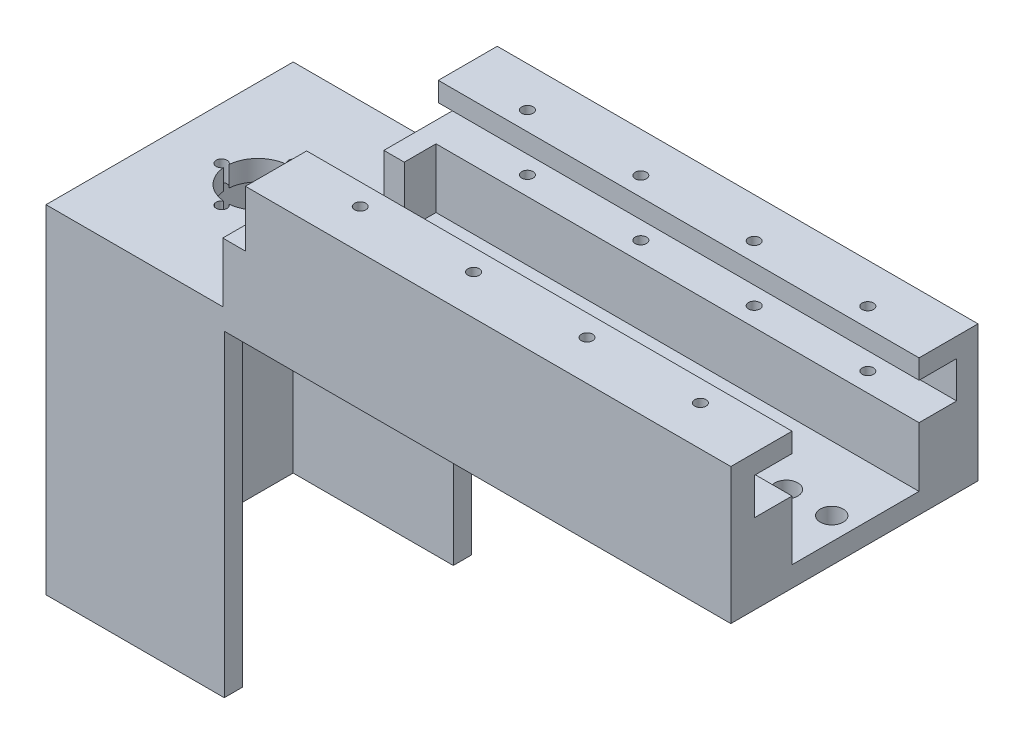
from build123d import *

# Parameters (mm, degrees)
SKETCH4_W                  = 106
SKETCH4_H                  = 30
BOSS_EXTRUDE2_DEPTH        = 13
SKETCH25_W                 = 106
SKETCH25_H                 = 8.1
CUT_EXTRUDE3_DEPTH         = 1
CUT_EXTRUDE3_DEPTH_BACK    = 8.3
M3X0_5_TAPPED_HOLE1_D      = 2.5
SKETCH28_W                 = 106
SKETCH28_H                 = 4.5
BOSS_EXTRUDE3_DEPTH        = 41.5
SKETCH32_W                 = 41.5
SKETCH32_H                 = 4.5
BOSS_EXTRUDE10_DEPTH       = 5
SKETCH33_W                 = 13
SKETCH33_H                 = 17.621445937
BOSS_EXTRUDE12_DEPTH       = 5
SKETCH34_W                 = 4.498886861
SKETCH34_H                 = 13.121445937
BOSS_EXTRUDE13_DEPTH       = 7
SKETCH35_W                 = 54.5
SKETCH35_H                 = 4.5
BOSS_EXTRUDE14_DEPTH       = 40
SKETCH36_W                 = 5
SKETCH36_H                 = 20
BOSS_EXTRUDE15_DEPTH       = 13.12
F_8_0_199_DIAMETER_HOLE1_D = 5.0546
SKETCH39_R                 = 7
CUT_EXTRUDE4_DEPTH         = 10
M2_CLEARANCE_HOLE1_D       = 2.4
SKETCH43_W                 = 35.304815243
SKETCH43_H                 = 4
BOSS_EXTRUDE16_DEPTH       = 70
SKETCH44_W                 = 107.027081708
SKETCH44_H                 = 13.5
BOSS_EXTRUDE17_DEPTH       = 25.5
SKETCH47_W                 = 107.027081708
SKETCH47_H                 = 8.1
CUT_EXTRUDE5_DEPTH         = 8.3
M3X0_5_TAPPED_HOLE2_D      = 2.5


with BuildPart() as part:
    # Sketch4 → Boss-Extrude2 (new body)
    with BuildSketch(Plane.XY):
        with Locations((-36.891047602, -35.322762913)):
            Rectangle(SKETCH4_W, SKETCH4_H)
    extrude(amount=-BOSS_EXTRUDE2_DEPTH)

    # Sketch25 → Cut-Extrude3 (cut, two sides)
    with BuildSketch(Plane.XY) as cut_extrude3_sk:
        with Locations((-36.891047602, -28.651316976)):
            Rectangle(SKETCH25_W, SKETCH25_H)
    extrude(amount=CUT_EXTRUDE3_DEPTH, mode=Mode.SUBTRACT)
    extrude(cut_extrude3_sk.sketch, amount=-CUT_EXTRUDE3_DEPTH_BACK, mode=Mode.SUBTRACT)

    # M3x0.5 Tapped Hole1 (through all)
    with Locations(Plane(origin=(-74.390985602, -20.322762913, -4.15), x_dir=(0, 0, 1), z_dir=(0, 1, 0))):
        with Locations((0, 0), (0, 25), (-0.055677319, 74.999938), (0, 50)):
            Hole(M3X0_5_TAPPED_HOLE1_D / 2)

    # Sketch28 → Boss-Extrude3 (add)
    with BuildSketch(Plane.XY):
        with Locations((-36.891047602, -48.072762913)):
            Rectangle(SKETCH28_W, SKETCH28_H)
    extrude(amount=BOSS_EXTRUDE3_DEPTH)

    # Sketch32 → Boss-Extrude10 (add)
    with BuildSketch(Plane.ZY.offset(89.891047602)):
        with Locations((20.75, -48.072762913)):
            Rectangle(SKETCH32_W, SKETCH32_H)
    extrude(amount=BOSS_EXTRUDE10_DEPTH)

    # Sketch33 → Boss-Extrude12 (add)
    with BuildSketch(Plane.ZY.offset(89.891047602)):
        with Locations((-6.5, -41.512039945)):
            Rectangle(SKETCH33_W, SKETCH33_H)
    extrude(amount=BOSS_EXTRUDE12_DEPTH)

    # Sketch34 → Boss-Extrude13 (add)
    with BuildSketch(Plane.XY):
        with Locations((-92.641604172, -39.262039945)):
            Rectangle(SKETCH34_W, SKETCH34_H)
    extrude(amount=BOSS_EXTRUDE13_DEPTH)

    # Sketch35 → Boss-Extrude14 (add)
    with BuildSketch(Plane.ZY.offset(94.891047602)):
        with Locations((14.25, -48.072762913)):
            Rectangle(SKETCH35_W, SKETCH35_H)
    extrude(amount=BOSS_EXTRUDE14_DEPTH)

    # Sketch36 → Boss-Extrude15 (add)
    with BuildSketch(Plane(origin=(0, -45.822762913, 0), x_dir=(1, 0, 0), z_dir=(0, 1, 0))):
        with Locations((-93.41812931, -31.5)):
            Rectangle(SKETCH36_W, SKETCH36_H)
    extrude(amount=BOSS_EXTRUDE15_DEPTH)

    # #8 (0.199) Diameter Hole1 (through all)
    with Locations(Plane(origin=(-80.669073904, -45.822762913, 14.25), x_dir=(0, 0, 1), z_dir=(0, 1, 0))):
        with Locations((0, 0), (0, 91.778026302), (0, 81.778026302), (0, 10)):
            Hole(F_8_0_199_DIAMETER_HOLE1_D / 2)

    # Sketch39 → Cut-Extrude4 (cut)
    with BuildSketch(Plane(origin=(0, -45.822762913, 0), x_dir=(1, 0, 0), z_dir=(0, 1, 0))):
        with Locations((-115.41812931, -14.25)):
            Circle(SKETCH39_R)
    extrude(amount=-CUT_EXTRUDE4_DEPTH, mode=Mode.SUBTRACT)

    # M2 Clearance Hole1 (through all)
    with Locations(Plane(origin=(-107.41812931, -45.822762913, 14.25), x_dir=(0, 0, 1), z_dir=(0, 1, 0))):
        with Locations((0, 0), (8.000007036, -8.002918292), (-7.999992964, -8.002918292), (0, -16)):
            Hole(M2_CLEARANCE_HOLE1_D / 2)

    # Sketch43 → Boss-Extrude16 (add)
    with BuildSketch(Plane(origin=(0, -50.322762913, 0), x_dir=(-1, 0, 0), z_dir=(0, -1, 0))):
        Polygon((95.586232359, -37.5), (95.586232359, -41.5), (134.891047602, -41.5), (134.891047602, -37.5), (130.891047602, -37.5), align=None)
        Polygon((130.891047602, -37.5), (134.891047602, -37.5), (134.891047602, 13), (130.891047602, 13), (130.891047602, 9), align=None)
        with Locations((113.238639981, 11)):
            Rectangle(SKETCH43_W, SKETCH43_H)
    extrude(amount=BOSS_EXTRUDE16_DEPTH)

    # Sketch44 → Boss-Extrude17 (add)
    with BuildSketch(Plane(origin=(0, -45.822762913, 0), x_dir=(1, 0, 0), z_dir=(0, 1, 0))):
        with Locations((-37.404588456, -34.75)):
            Rectangle(SKETCH44_W, SKETCH44_H)
    extrude(amount=BOSS_EXTRUDE17_DEPTH)

    # Sketch47 → Cut-Extrude5 (cut)
    with BuildSketch(Plane(origin=(0, 0, 28), x_dir=(-1, 0, 0), z_dir=(0, 0, -1))):
        with Locations((37.404588456, -28.652762913)):
            Rectangle(SKETCH47_W, SKETCH47_H)
    extrude(amount=-CUT_EXTRUDE5_DEPTH, mode=Mode.SUBTRACT)

    # M3x0.5 Tapped Hole2 (through all)
    with Locations(Plane(origin=(-74.391047602, -20.322762913, 32.71), x_dir=(0, 0, 1), z_dir=(0, 1, 0))):
        with Locations((0, 0), (0, 25), (0, 50), (0, 75)):
            Hole(M3X0_5_TAPPED_HOLE2_D / 2)


solid = part.part
